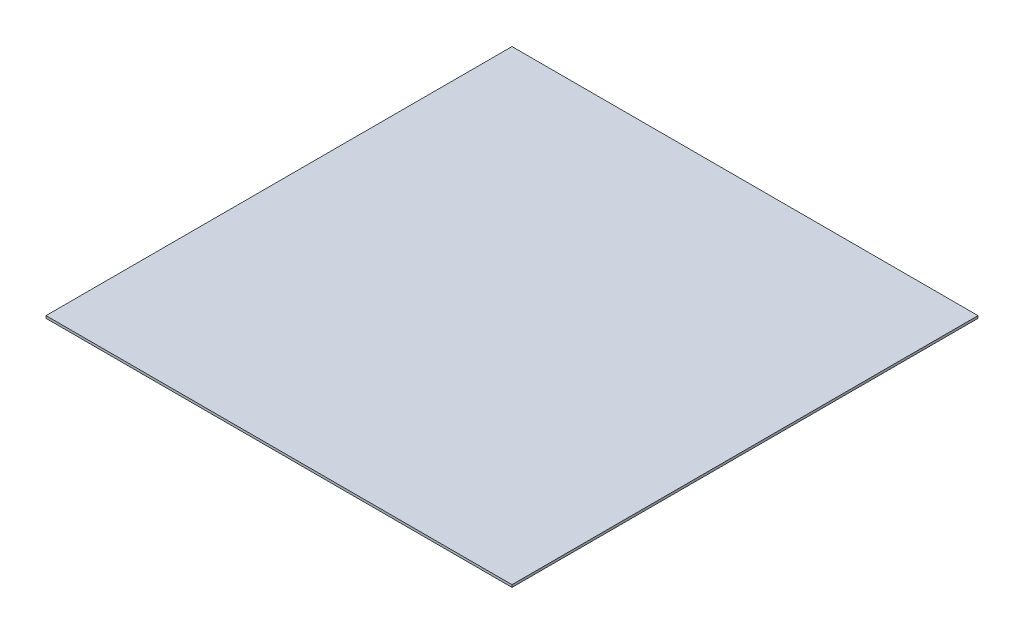
from build123d import *

# Parameters (mm, degrees)
SKETCH1_W           = 152.4
SKETCH1_H           = 152.4
BOSS_EXTRUDE1_DEPTH = 0.79375


with BuildPart() as part:
    # Sketch1 → Boss-Extrude1 (new body)
    with BuildSketch(Plane(origin=(0, 0, 0), x_dir=(1, 0, 0), z_dir=(0, 1, 0))):
        Rectangle(SKETCH1_W, SKETCH1_H)
    extrude(amount=BOSS_EXTRUDE1_DEPTH)


solid = part.part
